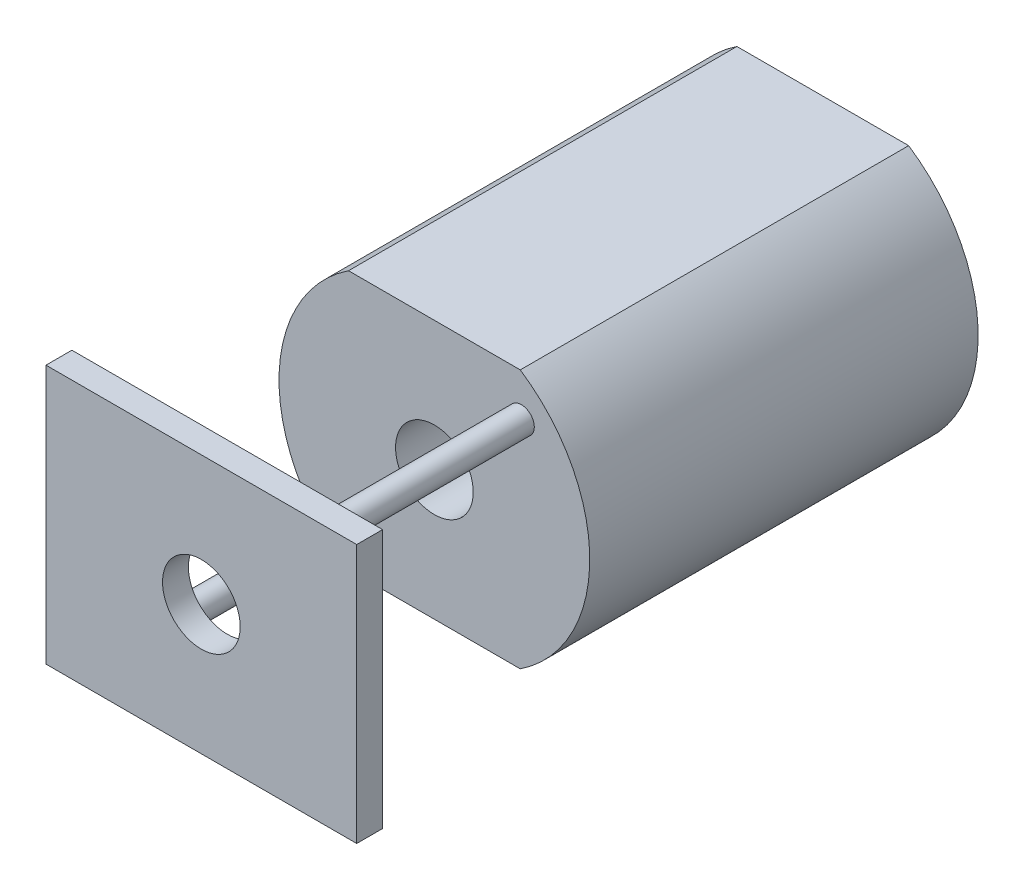
from build123d import *

# Parameters (mm, degrees)
BOSS_EXTRUDE1_DEPTH = 7.5
SKETCH2_R           = 2.5
BOSS_EXTRUDE2_DEPTH = 1
SKETCH3_R           = 0.5
BOSS_EXTRUDE3_DEPTH = 9
SKETCH4_W           = 12
SKETCH4_H           = 10
BOSS_EXTRUDE4_DEPTH = 1
SKETCH5_R           = 1.5
CUT_EXTRUDE1_DEPTH  = 26


with BuildPart() as part:
    # Sketch1 → Boss-Extrude1 (new body, symmetric)
    with BuildSketch(Plane.XY):
        with BuildLine():
            Line((-3.31662479, 5), (3.31662479, 5))
            ThreePointArc((3.31662479, 5), (6, 0), (3.31662479, -5))
            Line((3.31662479, -5), (-3.31662479, -5))
            ThreePointArc((-3.31662479, -5), (-6, 0), (-3.31662479, 5))
        make_face()
    extrude(amount=BOSS_EXTRUDE1_DEPTH, both=True)

    # Sketch2 → Boss-Extrude2 (add)
    with BuildSketch(Plane(origin=(0, 0, -7.5), x_dir=(-1, 0, 0), z_dir=(0, 0, -1))):
        Circle(SKETCH2_R)
    extrude(amount=BOSS_EXTRUDE2_DEPTH)

    # Sketch3 → Boss-Extrude3 (add)
    with BuildSketch(Plane.XY.offset(7.5)):
        with Locations((3.358757211, 3.358757211)):
            Circle(SKETCH3_R)
        with Locations((-3.358757211, -3.358757211)):
            Circle(SKETCH3_R)
    extrude(amount=BOSS_EXTRUDE3_DEPTH)

    # Sketch4 → Boss-Extrude4 (add)
    with BuildSketch(Plane.XY.offset(16.5)):
        Rectangle(SKETCH4_W, SKETCH4_H)
    extrude(amount=-BOSS_EXTRUDE4_DEPTH)

    # Sketch5 → Cut-Extrude1 (cut, through all)
    with BuildSketch(Plane.XY.offset(16.5)):
        Circle(SKETCH5_R)
    extrude(amount=-CUT_EXTRUDE1_DEPTH, mode=Mode.SUBTRACT)


solid = part.part
